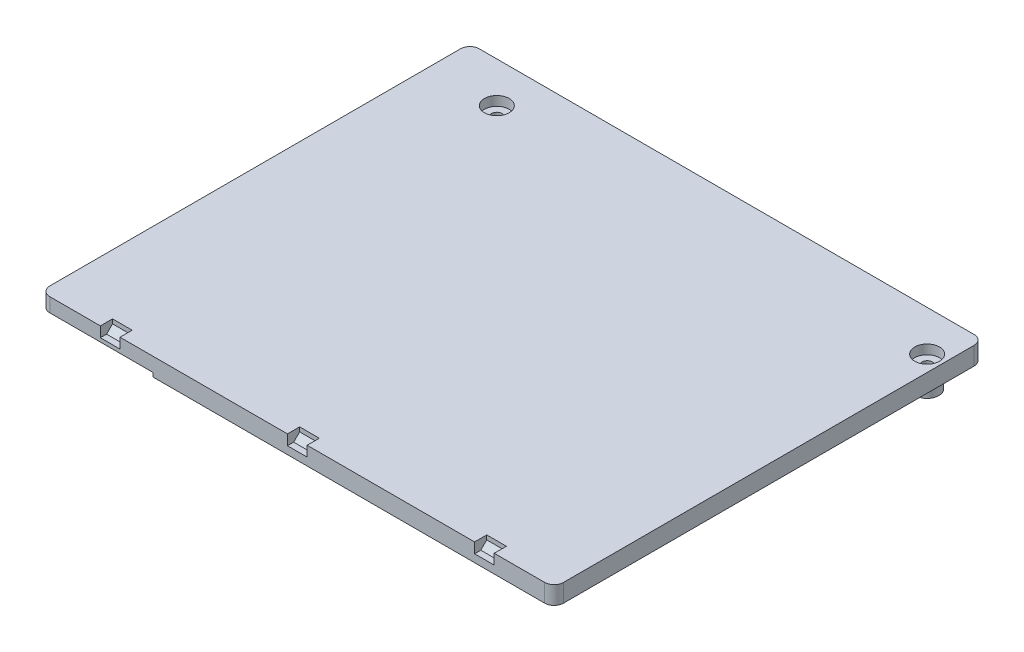
from build123d import *

# Parameters (mm, degrees)
EXTRUDE_1_DEPTH        = 3.85
SKETCH_2_R             = 1.1
CUT_EXTRUDE_1_DEPTH    = 4.85
CUT_EXTRUDE_2_DEPTH    = 2.1
PATTERN_LINEAR_1_COUNT = 2
PATTERN_LINEAR_1_PITCH = 40
PATTERN_LINEAR_2_COUNT = 2
PATTERN_LINEAR_2_PITCH = 40
SKETCH_7_R             = 2.5
SKETCH_7_R_2           = 1.1
EXTRUDE_2_DEPTH        = 2.6
SKETCH_8_R             = 2.65
CUT_EXTRUDE_5_DEPTH    = 2
SKETCH_5_W             = 17
SKETCH_5_H             = 23
CUT_EXTRUDE_3_DEPTH    = 1.85
SKETCH_6_R             = 4
CUT_EXTRUDE_4_DEPTH    = 1.85
SKETCH_9_W             = 24
SKETCH_9_H             = 67
CUT_EXTRUDE_6_DEPTH    = 0.85
SKETCH_10_R            = 3
CUT_EXTRUDE_7_DEPTH    = 2.65
SKETCH_11_R            = 4.5
CUT_EXTRUDE_8_DEPTH    = 2.85


with BuildPart() as part:
    # 草图1 → 凸台-拉伸1 (new body)
    with BuildSketch(Plane(origin=(0, 0, 0), x_dir=(1, 0, 0), z_dir=(0, 1, 0))):
        with BuildLine():
            Line((-52.9, -45.9), (52.9, -45.9))
            ThreePointArc((52.9, -45.9), (54.314213562, -45.314213562), (54.9, -43.9))
            Line((54.9, -43.9), (54.9, 43.9))
            ThreePointArc((54.9, 43.9), (54.314213562, 45.314213562), (52.9, 45.9))
            Line((52.9, 45.9), (-52.9, 45.9))
            ThreePointArc((-52.9, 45.9), (-54.314213562, 45.314213562), (-54.9, 43.9))
            Line((-54.9, 43.9), (-54.9, -43.9))
            ThreePointArc((-54.9, -43.9), (-54.314213562, -45.314213562), (-52.9, -45.9))
        make_face()
    extrude(amount=EXTRUDE_1_DEPTH)

    # 草图2 → 切除-拉伸1 (cut, through all)
    with BuildSketch(Plane(origin=(0, 3.85, 0), x_dir=(1, 0, 0), z_dir=(0, 1, 0))):
        with Locations((-40.5, 37.25)):
            Circle(SKETCH_2_R)
        with Locations((51.5, 37.25)):
            Circle(SKETCH_2_R)
    extrude(amount=-CUT_EXTRUDE_1_DEPTH, mode=Mode.SUBTRACT)

    # 草图3 → 切除-拉伸2 (cut, symmetric)
    with BuildSketch(Plane(origin=(0, 0, 0), x_dir=(0, 0, -1), z_dir=(1, 0, 0))):
        Polygon((-45.9, 3.85), (-43.3, 3.85), (-43.3, 2.922792206), (-44.572792206, 1.65), (-45.9, 1.65), align=None)
    cut_extrude_2 = extrude(amount=CUT_EXTRUDE_2_DEPTH, both=True, mode=Mode.SUBTRACT)

    # 阵列(线性)1: 切除-拉伸2 ×2
    with Locations(*[(i * PATTERN_LINEAR_1_PITCH, 0, 0) for i in range(1, PATTERN_LINEAR_1_COUNT)]):
        add(cut_extrude_2, mode=Mode.SUBTRACT)

    # 阵列(线性)2: 切除-拉伸2 ×2
    with Locations(*[(-i * PATTERN_LINEAR_2_PITCH, 0, 0) for i in range(1, PATTERN_LINEAR_2_COUNT)]):
        add(cut_extrude_2, mode=Mode.SUBTRACT)

    # 草图7 → 凸台-拉伸2 (add)
    with BuildSketch(Plane.XZ):
        with Locations((-40.5, -37.25)):
            Circle(SKETCH_7_R)
        with Locations((-40.5, -37.25)):
            Circle(SKETCH_7_R_2, mode=Mode.SUBTRACT)
        with Locations((51.5, -37.25)):
            Circle(SKETCH_7_R)
        with Locations((51.5, -37.25)):
            Circle(SKETCH_7_R_2, mode=Mode.SUBTRACT)
        with Locations((-11.5, 19.75)):
            Circle(SKETCH_7_R)
        with Locations((-22.5, -14.25)):
            Circle(SKETCH_7_R)
        with Locations((12.5, 8.75)):
            Circle(SKETCH_7_R)
        with BuildLine():
            Line((-28.5, 40.9), (-1.5, 40.9))
            ThreePointArc((-1.5, 40.9), (0.5, 38.9), (-1.5, 36.9))
            Line((-1.5, 36.9), (-28.5, 36.9))
            ThreePointArc((-28.5, 36.9), (-30.5, 38.9), (-28.5, 40.9))
        make_face()
        with BuildLine():
            Line((47.5, 28.75), (47.5, 6.75))
            ThreePointArc((47.5, 6.75), (45.5, 4.75), (43.5, 6.75))
            Line((43.5, 6.75), (43.5, 28.75))
            ThreePointArc((43.5, 28.75), (45.5, 30.75), (47.5, 28.75))
        make_face()
        with BuildLine():
            Line((-7.5, -35.75), (42.5, -35.75))
            ThreePointArc((42.5, -35.75), (44.5, -37.75), (42.5, -39.75))
            Line((42.5, -39.75), (-7.5, -39.75))
            ThreePointArc((-7.5, -39.75), (-9.5, -37.75), (-7.5, -35.75))
        make_face()
    extrude(amount=EXTRUDE_2_DEPTH)

    # 草图8 → 切除-拉伸5 (cut)
    with BuildSketch(Plane(origin=(0, 3.85, 0), x_dir=(1, 0, 0), z_dir=(0, 1, 0))):
        with Locations((-40.5, 37.25)):
            Circle(SKETCH_8_R)
        with Locations((51.5, 37.25)):
            Circle(SKETCH_8_R)
    extrude(amount=-CUT_EXTRUDE_5_DEPTH, mode=Mode.SUBTRACT)

    # 草图5 → 切除-拉伸3 (cut)
    with BuildSketch(Plane.XZ):
        with Locations((28, 32.25)):
            Rectangle(SKETCH_5_W, SKETCH_5_H)
    extrude(amount=-CUT_EXTRUDE_3_DEPTH, mode=Mode.SUBTRACT)

    # 草图6 → 切除-拉伸4 (cut)
    with BuildSketch(Plane.XZ):
        with Locations((46.5, 0.75)):
            Circle(SKETCH_6_R)
    extrude(amount=-CUT_EXTRUDE_4_DEPTH, mode=Mode.SUBTRACT)

    # 草图9 → 切除-拉伸6 (cut)
    with BuildSketch(Plane.XZ):
        with Locations((-42.9, 12.4)):
            Rectangle(SKETCH_9_W, SKETCH_9_H)
    extrude(amount=-CUT_EXTRUDE_6_DEPTH, mode=Mode.SUBTRACT)

    # 草图10 → 切除-拉伸7 (cut)
    with BuildSketch(Plane.XZ):
        with Locations((-37.4, 11.75)):
            Circle(SKETCH_10_R)
        with Locations((-37.4, -16.75)):
            Circle(SKETCH_10_R)
    extrude(amount=-CUT_EXTRUDE_7_DEPTH, mode=Mode.SUBTRACT)

    # 草图11 → 切除-拉伸8 (cut)
    with BuildSketch(Plane.XZ):
        with Locations((-26.5, 6.75)):
            Circle(SKETCH_11_R)
    extrude(amount=-CUT_EXTRUDE_8_DEPTH, mode=Mode.SUBTRACT)


solid = part.part
